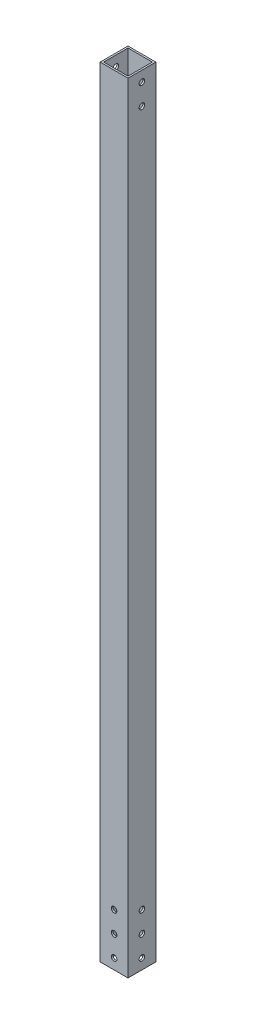
from build123d import *

# Parameters (mm, degrees)
SKETCH1_W           = 25.4
SKETCH1_H           = 25.4
SKETCH1_W_2         = 22.225
SKETCH1_H_2         = 22.225
BOSS_EXTRUDE1_DEPTH = 711.2
SKETCH2_R           = 2.5527
CUT_EXTRUDE1_DEPTH  = 26.4
SKETCH3_R           = 2.5527
CUT_EXTRUDE2_DEPTH  = 26.4


with BuildPart() as part:
    # Sketch1 → Boss-Extrude1 (new body)
    with BuildSketch(Plane(origin=(0, 0, 0), x_dir=(1, 0, 0), z_dir=(0, 1, 0))):
        Rectangle(SKETCH1_W, SKETCH1_H)
        Rectangle(SKETCH1_W_2, SKETCH1_H_2, mode=Mode.SUBTRACT)
    extrude(amount=BOSS_EXTRUDE1_DEPTH)

    # Sketch2 → Cut-Extrude1 (cut, through all)
    with BuildSketch(Plane.XY.offset(12.7)):
        with Locations((0, 9.525)):
            Circle(SKETCH2_R)
        with Locations((0, 28.575)):
            Circle(SKETCH2_R)
        with Locations((0, 47.625)):
            Circle(SKETCH2_R)
    extrude(amount=-CUT_EXTRUDE1_DEPTH, mode=Mode.SUBTRACT)

    # Sketch3 → Cut-Extrude2 (cut, through all)
    with BuildSketch(Plane(origin=(12.7, 0, 0), x_dir=(0, 0, -1), z_dir=(1, 0, 0))):
        with Locations((0, 9.525)):
            Circle(SKETCH3_R)
        with Locations((0, 28.575)):
            Circle(SKETCH3_R)
        with Locations((0, 47.625)):
            Circle(SKETCH3_R)
        with Locations((0, 701.675)):
            Circle(SKETCH3_R)
        with Locations((0, 682.625)):
            Circle(SKETCH3_R)
    extrude(amount=-CUT_EXTRUDE2_DEPTH, mode=Mode.SUBTRACT)


solid = part.part
